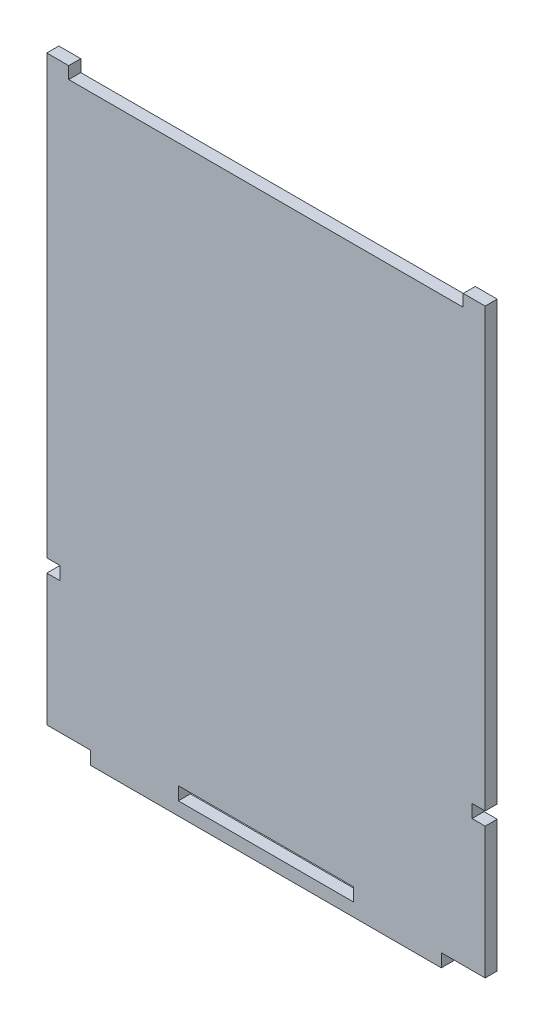
from build123d import *

# Parameters (mm, degrees)
SKETCH_1_W      = 5
SKETCH_1_H      = 2.75
EXTRUDE_1_DEPTH = 2.75


with BuildPart() as part:
    # 草图1 → 凸台-拉伸1 (new body)
    with BuildSketch(Plane.XY):
        Polygon((95, 100), (100, 100), (100, 102.75), (95, 102.75), (95, 102.449578136), align=None)
        Polygon((3, 3), (3, 0), (97, 0), (97, 3), (100, 3), (100, 100), (95, 100), (5, 100), (0, 100), (0, 3), align=None)
        with Locations((2.5, 101.375)):
            Rectangle(SKETCH_1_W, SKETCH_1_H)
        Polygon((0, 0), (0, -30), (10, -30), (30, -30), (30, -27), (50, -27), (70, -27), (70, -30), (90, -30), (100, -30), (100, 0), (97, 0), (3, 0), align=None)
        Polygon((30, -30), (10, -30), (10, -33), (90, -33), (90, -30), (70, -30), (50, -30), align=None)
    extrude(amount=EXTRUDE_1_DEPTH)


solid = part.part
